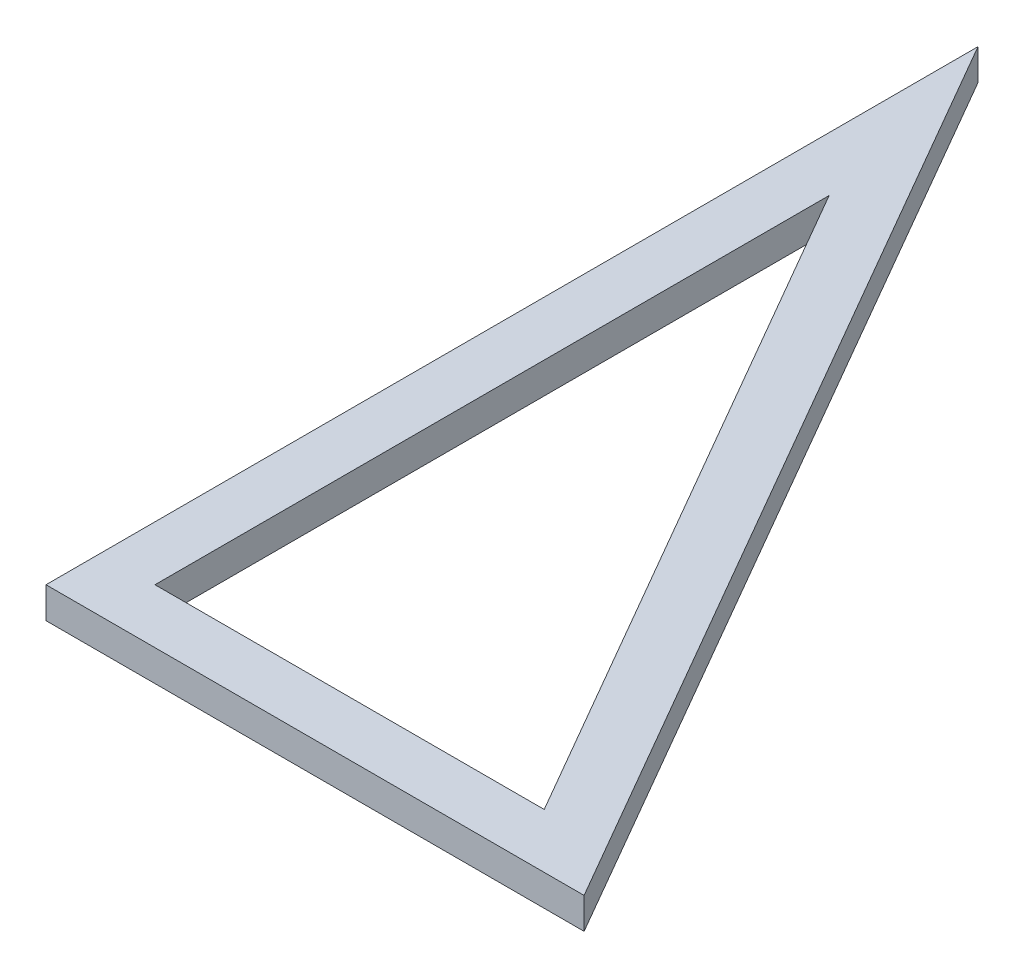
from build123d import *

# Parameters (mm, degrees)
EXTRUDE_1_DEPTH = 4


with BuildPart() as part:
    # 草图1 → 凸台-拉伸1 (new body)
    with BuildSketch(Plane(origin=(0, 0, 0), x_dir=(1, 0, 0), z_dir=(0, 1, 0))):
        Polygon((62.124355653, -7), (-7, 112.726896031), (-7, -7), align=None)
        Polygon((0, 86.602540378), (0, 0), (50, 0), align=None, mode=Mode.SUBTRACT)
    extrude(amount=EXTRUDE_1_DEPTH)


solid = part.part
